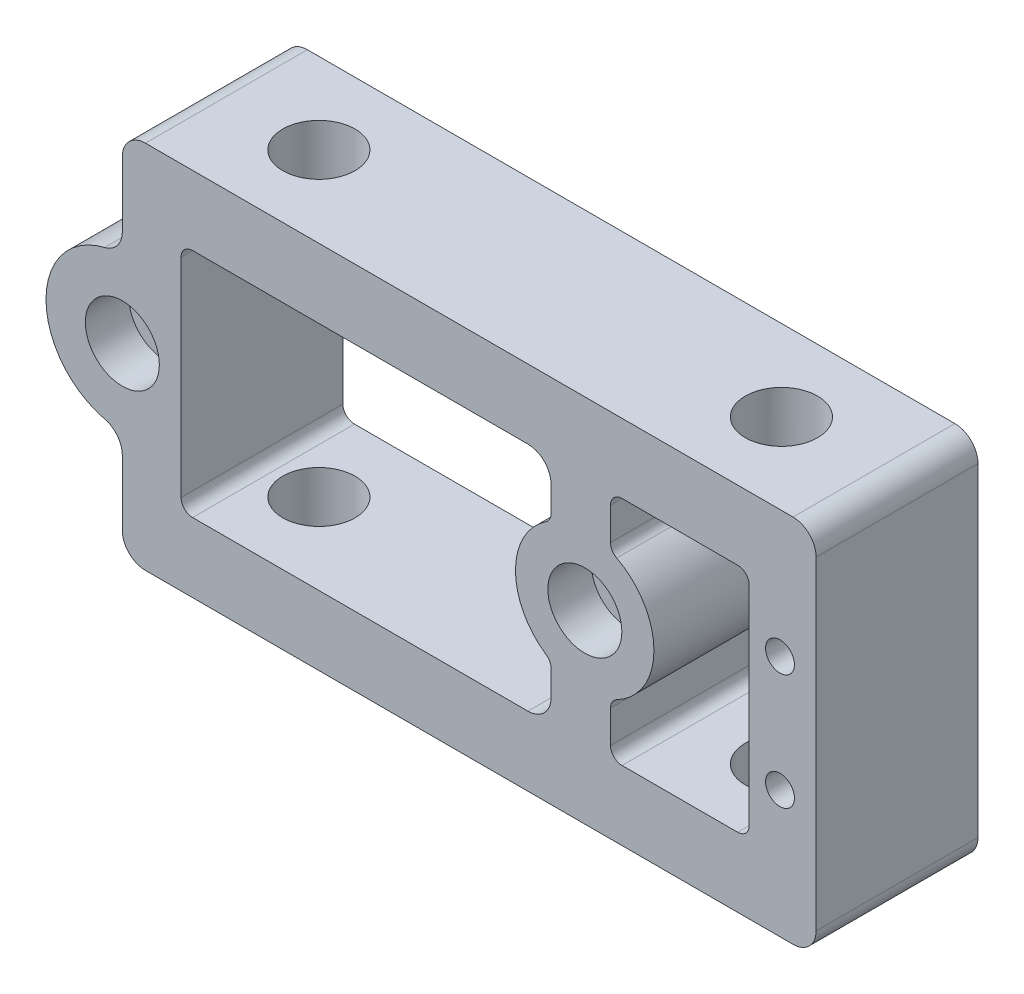
from build123d import *

# Parameters (mm, degrees)
SKETCH1_W           = 93.6625
SKETCH1_H           = 40.64
SKETCH1_R           = 2.4892
SKETCH1_R_2         = 1.5875
BOSS_EXTRUDE1_DEPTH = 17.78
SKETCH6_R           = 3.96875
CUT_EXTRUDE4_DEPTH  = 41.64
CUT_EXTRUDE3_DEPTH  = 17.78
FILLET1_R           = 2.54
SKETCH3_R           = 4.064
CUT_EXTRUDE5_DEPTH  = 4.7752
SKETCH7_W           = 9.113549332
SKETCH7_H           = 21.245092044
CUT_EXTRUDE6_DEPTH  = 18.78
SKETCH8_W           = 17.78
SKETCH8_H           = 25.4
CUT_EXTRUDE7_DEPTH  = 17.78
FILLET2_R           = 1.27


with BuildPart() as part:
    # Sketch1 → Boss-Extrude1 (new body)
    with BuildSketch(Plane.XY):
        with Locations((-46.83125, 0)):
            Rectangle(SKETCH1_W, SKETCH1_H)
        with Locations((-84.93125, 0)):
            Circle(SKETCH1_R, mode=Mode.SUBTRACT)
        with Locations((-34.13125, 0)):
            Circle(SKETCH1_R, mode=Mode.SUBTRACT)
        with Locations((-12.7, 6.35)):
            Circle(SKETCH1_R_2, mode=Mode.SUBTRACT)
        with Locations((-12.7, -6.35)):
            Circle(SKETCH1_R_2, mode=Mode.SUBTRACT)
    extrude(amount=-BOSS_EXTRUDE1_DEPTH)

    # Sketch6 → Cut-Extrude4 (cut, through all)
    with BuildSketch(Plane(origin=(0, 20.32, 0), x_dir=(1, 0, 0), z_dir=(0, 1, 0))):
        with Locations((-72.23125, 8.89)):
            Circle(SKETCH6_R)
        with Locations((-21.43125, 8.89)):
            Circle(SKETCH6_R)
    extrude(amount=-CUT_EXTRUDE4_DEPTH, mode=Mode.SUBTRACT)

    # Sketch5 → Cut-Extrude3 (cut)
    with BuildSketch(Plane.XY):
        with BuildLine():
            Line((-93.6625, -20.32), (-93.6625, 20.32))
            Line((-93.6625, 20.32), (-84.93125, 20.32))
            Line((-84.93125, 20.32), (-84.93125, 10.622546022))
            ThreePointArc((-84.93125, 10.622546022), (-85.477262526, 9.049137635), (-86.880552326, 8.152186482))
            ThreePointArc((-86.880552326, 8.152186482), (-93.31325, 0), (-86.880552326, -8.152186482))
            ThreePointArc((-86.880552326, -8.152186482), (-85.477262526, -9.049137635), (-84.93125, -10.622546022))
            Line((-84.93125, -10.622546022), (-84.93125, -20.32))
            Line((-84.93125, -20.32), (-93.6625, -20.32))
        make_face()
        with BuildLine():
            Line((0, -20.32), (0, 20.32))
            Line((0, 20.32), (-8.73125, 20.32))
            Line((-8.73125, 20.32), (-8.73125, 10.622546022))
            ThreePointArc((-8.73125, 10.622546022), (-8.185237474, 9.049137635), (-6.781947674, 8.152186482))
            ThreePointArc((-6.781947674, 8.152186482), (-0.34925, 0), (-6.781947674, -8.152186482))
            ThreePointArc((-6.781947674, -8.152186482), (-8.185237474, -9.049137635), (-8.73125, -10.622546022))
            Line((-8.73125, -10.622546022), (-8.73125, -20.32))
            Line((-8.73125, -20.32), (0, -20.32))
        make_face()
    extrude(amount=-CUT_EXTRUDE3_DEPTH, mode=Mode.SUBTRACT)

    # Fillet1
    fillet1_edges = [part.edges().sort_by_distance(p)[0] for p in [
        (-84.93125, 20.32, -8.89),
        (-84.93125, -20.32, -8.89),
        (-8.73125, 20.32, -8.89),
        (-8.73125, -20.32, -8.89),
    ]]
    fillet(fillet1_edges, radius=FILLET1_R)

    # Sketch3 → Cut-Extrude5 (cut)
    with BuildSketch(Plane.XY):
        with Locations((-84.93125, 0)):
            Circle(SKETCH3_R)
        with Locations((-34.13125, 0)):
            Circle(SKETCH3_R)
    extrude(amount=-CUT_EXTRUDE5_DEPTH, mode=Mode.SUBTRACT)

    # Sketch7 → Cut-Extrude6 (cut, through all)
    with BuildSketch(Plane.XY):
        with BuildLine():
            Line((-37.842518981, 10.16), (-37.842518981, 6.655139559))
            ThreePointArc((-37.842518981, 6.655139559), (-41.75125, 0), (-37.842518981, -6.655139559))
            Line((-37.842518981, -6.655139559), (-37.842518981, -10.16))
            ThreePointArc((-37.842518981, -10.16), (-38.586467757, -11.956051224), (-40.382518981, -12.7))
            Line((-40.382518981, -12.7), (-60.702518981, -12.7))
            ThreePointArc((-60.702518981, -12.7), (-62.498570205, -11.956051224), (-63.242518981, -10.16))
            Line((-63.242518981, -10.16), (-63.242518981, 10.16))
            ThreePointArc((-63.242518981, 10.16), (-62.498570205, 11.956051224), (-60.702518981, 12.7))
            Line((-60.702518981, 12.7), (-40.382518981, 12.7))
            ThreePointArc((-40.382518981, 12.7), (-38.586467757, 11.956051224), (-37.842518981, 10.16))
        make_face()
        with Locations((-4.174475334, 0)):
            Rectangle(SKETCH7_W, SKETCH7_H)
    extrude(amount=-CUT_EXTRUDE6_DEPTH, mode=Mode.SUBTRACT)

    # Sketch8 → Cut-Extrude7 (cut)
    with BuildSketch(Plane.XY):
        with Locations((-69.592518981, 0)):
            Rectangle(SKETCH8_W, SKETCH8_H)
        with BuildLine():
            Line((-31.316413003, 12.7), (-16.076413003, 12.7))
            Line((-16.076413003, 12.7), (-16.076413003, -12.7))
            Line((-16.076413003, -12.7), (-31.316413003, -12.7))
            Line((-31.316413003, -12.7), (-31.316413003, -7.046567735))
            ThreePointArc((-31.316413003, -7.046567735), (-26.543271075, 0), (-31.316413003, 7.046567735))
            Line((-31.316413003, 7.046567735), (-31.316413003, 12.7))
        make_face()
    extrude(amount=-CUT_EXTRUDE7_DEPTH, mode=Mode.SUBTRACT)

    # Fillet2
    fillet2_edges = [part.edges().sort_by_distance(p)[0] for p in [
        (-37.842518981, 6.655139559, -8.89),
        (-37.842518981, -6.655139559, -8.89),
        (-78.482518981, 12.7, -8.89),
        (-78.482518981, -12.7, -8.89),
        (-16.076413003, -12.7, -8.89),
        (-31.316413003, 12.7, -8.89),
        (-31.316413003, -12.7, -8.89),
        (-16.076413003, 12.7, -8.89),
        (-31.316413003, 7.046567735, -8.89),
        (-31.316413003, -7.046567735, -8.89),
    ]]
    fillet(fillet2_edges, radius=FILLET2_R)


solid = part.part
